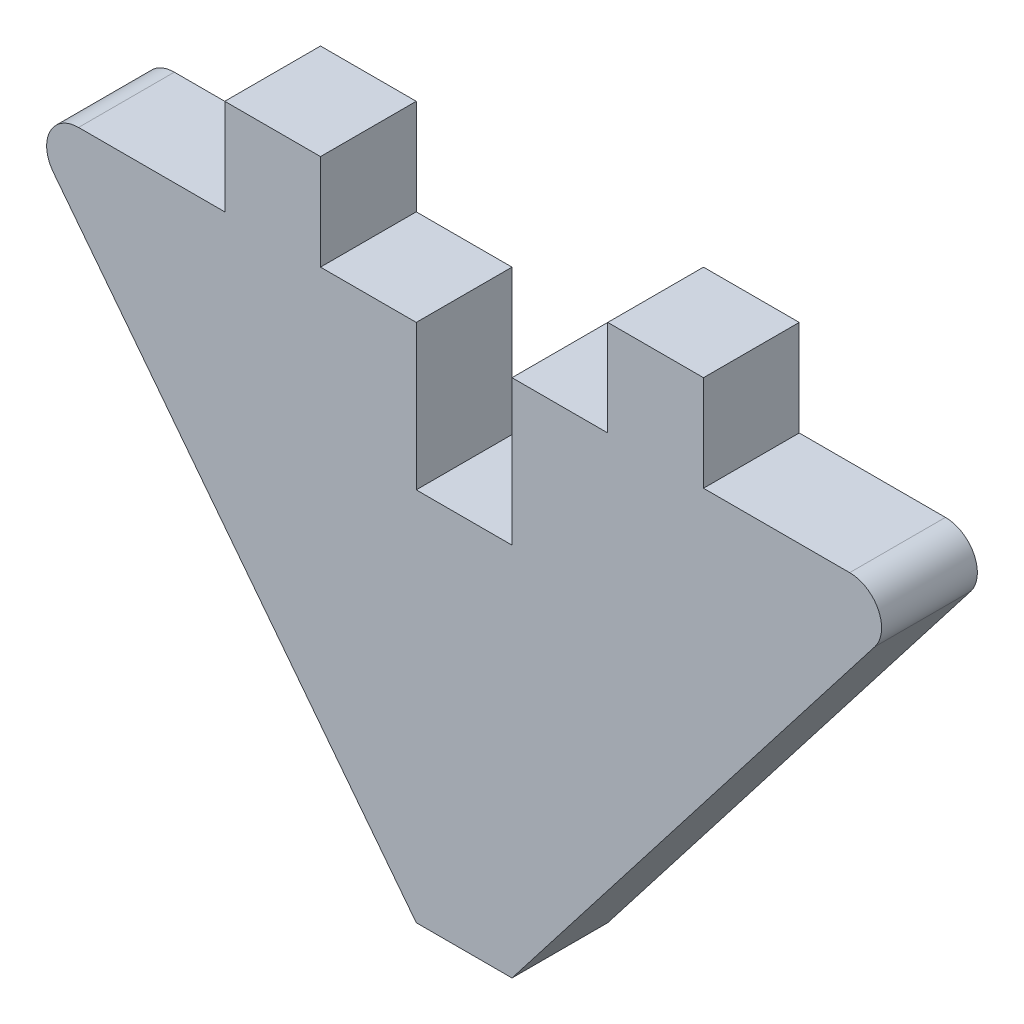
from build123d import *

# Parameters (mm, degrees)
BOSS_EXTRUDE1_DEPTH = 1.524


with BuildPart() as part:
    # Sketch1 → Boss-Extrude1 (new body)
    with BuildSketch(Plane.XY):
        with BuildLine():
            Line((1.524, 62.176210227), (1.524, 64.48445576))
            Line((1.524, 64.48445576), (3.048, 64.48445576))
            Line((3.048, 64.48445576), (3.048, 66.00845576))
            Line((3.048, 66.00845576), (4.572, 66.00845576))
            Line((4.572, 66.00845576), (4.572, 64.48445576))
            Line((4.572, 64.48445576), (6.898856883, 64.48445576))
            ThreePointArc((6.898856883, 64.48445576), (7.354991053, 64.200075123), (7.300433388, 63.665328277))
            Line((7.300433388, 63.665328277), (1.524, 56.209606557))
            Line((1.524, 56.209606557), (0, 56.209606557))
            Line((0, 56.209606557), (-5.776433388, 63.665328277))
            ThreePointArc((-5.776433388, 63.665328277), (-5.830991053, 64.200075123), (-5.374856883, 64.48445576))
            Line((-5.374856883, 64.48445576), (-3.048, 64.48445576))
            Line((-3.048, 64.48445576), (-3.048, 66.00845576))
            Line((-3.048, 66.00845576), (-1.524, 66.00845576))
            Line((-1.524, 66.00845576), (-1.524, 64.48445576))
            Line((-1.524, 64.48445576), (0, 64.48445576))
            Line((0, 64.48445576), (0, 62.176210227))
            Line((0, 62.176210227), (1.524, 62.176210227))
        make_face()
    extrude(amount=BOSS_EXTRUDE1_DEPTH)


solid = part.part
